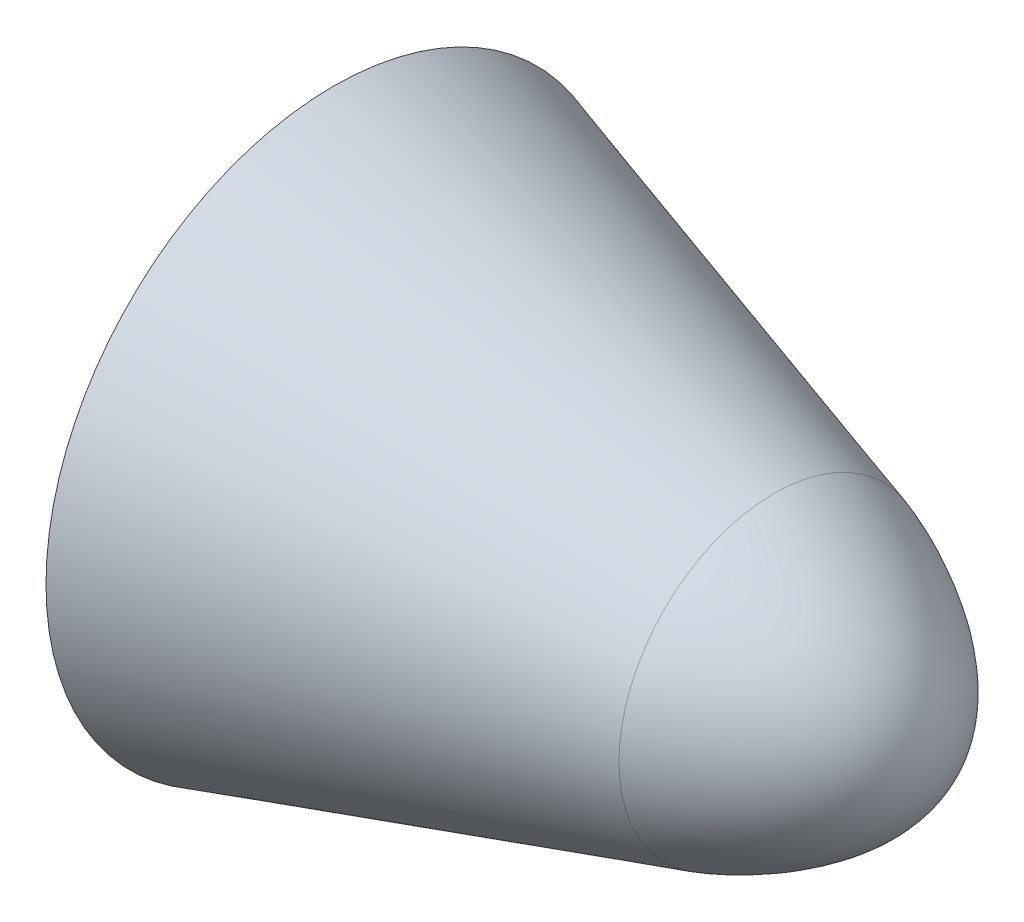
from build123d import *


with BuildPart() as part:
    # Sketch1 → Revolve1 (revolve)
    with BuildSketch(Plane.XY):
        with BuildLine():
            Line((3563.273055837, 697.146676222), (3951.753316429, 580.276670076))
            add(Edge.make_bspline(
                [(4092.306159962, 443.494261025), (4092.306159962, 523.659484664), (3981.110114694, 571.445000769), (3951.753316429, 580.276670076)],
                knots=[0, 0, 0, 0, 1, 1, 1, 1], degree=3))
            Line((4092.306159962, 443.494261025), (3563.273055837, 443.494261025))
            Line((3563.273055837, 443.494261025), (3563.273055837, 697.146676222))
        make_face()
    revolve(axis=Axis((3563.273055837, 443.494261025, 0), (1, 0, 0)))


solid = part.part
